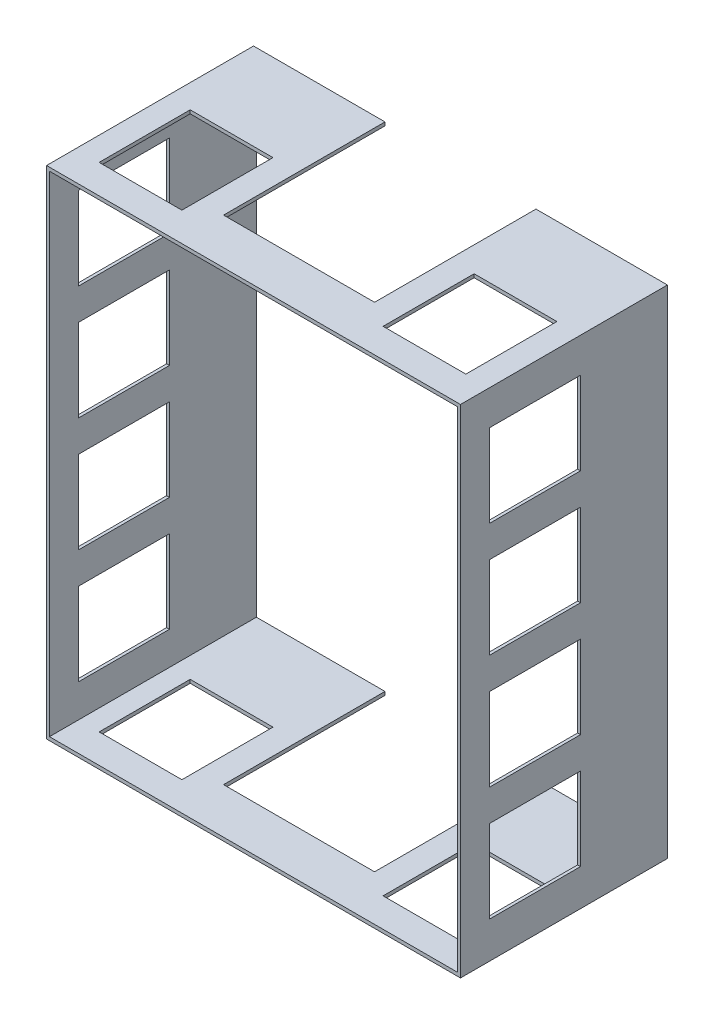
from build123d import *

# Parameters (mm, degrees)
SKETCH1_W           = 5000
SKETCH1_H           = 6000
SKETCH1_W_2         = 4930
SKETCH1_H_2         = 5916
BOSS_EXTRUDE1_DEPTH = 2500
SKETCH2_W           = 1100
SKETCH2_H           = 1000
CUT_EXTRUDE1_DEPTH  = 5531
CUT_EXTRUDE2_START  = -2597
SKETCH3_W           = 1000
SKETCH3_H           = 1100
CUT_EXTRUDE2_DEPTH  = 9647
SKETCH6_W           = 1824
SKETCH6_H           = 1950
CUT_EXTRUDE3_DEPTH  = 8265
LPATTERN2_COUNT     = 2
LPATTERN2_PITCH     = 3430
LPATTERN3_COUNT     = 4
LPATTERN3_PITCH     = 1380


with BuildPart() as part:
    # Sketch1 → Boss-Extrude1 (new body)
    with BuildSketch(Plane.XY.offset(38871.700196057)):
        with Locations((-27282.609122173, -1656.273034315)):
            Rectangle(SKETCH1_W, SKETCH1_H)
        with Locations((-27282.609122173, -1656.273034315)):
            Rectangle(SKETCH1_W_2, SKETCH1_H_2, mode=Mode.SUBTRACT)
    extrude(amount=BOSS_EXTRUDE1_DEPTH)

    # Sketch2 → Cut-Extrude1 (cut)
    with BuildSketch(Plane.ZY.offset(29782.609122173)):
        with Locations((40471.700196057, 424.5367891)):
            Rectangle(SKETCH2_W, SKETCH2_H)
    cut_extrude1 = extrude(amount=-CUT_EXTRUDE1_DEPTH, mode=Mode.SUBTRACT)

    # Sketch3 → Cut-Extrude2 (cut)
    with BuildSketch(Plane.XZ.offset(-1301.726965685).offset(CUT_EXTRUDE2_START)):
        with Locations((-25567.609122173, 40471.700196057)):
            Rectangle(SKETCH3_W, SKETCH3_H)
    cut_extrude2 = extrude(amount=CUT_EXTRUDE2_DEPTH, mode=Mode.SUBTRACT)

    # Sketch6 → Cut-Extrude3 (cut)
    with BuildSketch(Plane.XZ.offset(4656.273034315)):
        with Locations((-27282.609122173, 39846.700196057)):
            Rectangle(SKETCH6_W, SKETCH6_H)
    extrude(amount=-CUT_EXTRUDE3_DEPTH, mode=Mode.SUBTRACT)

    # LPattern2: Cut-Extrude2 ×2
    with Locations(*[(-i * LPATTERN2_PITCH, 0, 0) for i in range(1, LPATTERN2_COUNT)]):
        add(cut_extrude2, mode=Mode.SUBTRACT)

    # LPattern3: Cut-Extrude1 ×4
    with Locations(*[(0, -i * LPATTERN3_PITCH, 0) for i in range(1, LPATTERN3_COUNT)]):
        add(cut_extrude1, mode=Mode.SUBTRACT)


solid = part.part
